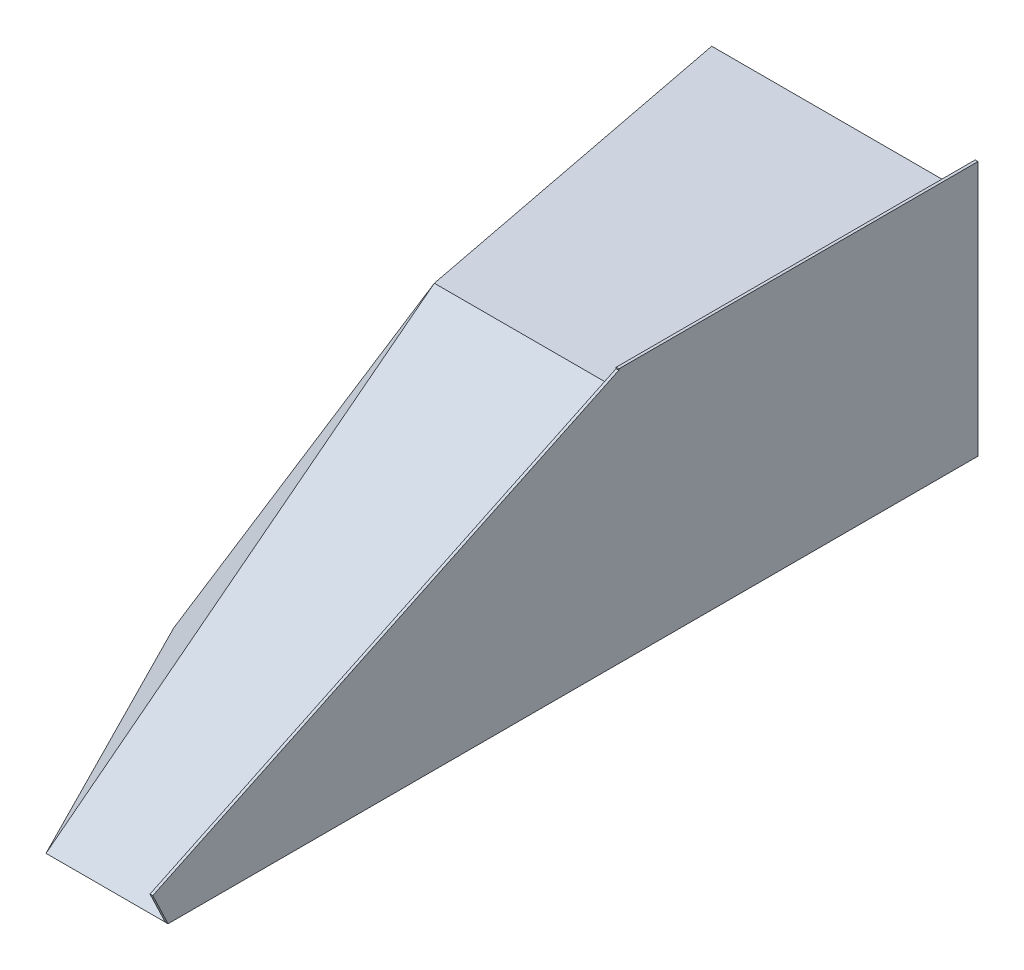
from build123d import *

# Parameters (mm, degrees)
BOSS_EXTRUDE1_DEPTH = 508
CUT_EXTRUDE1_DEPTH  = 508
BOSS_EXTRUDE2_DEPTH = 508
BOSS_EXTRUDE3_DEPTH = 635
CUT_EXTRUDE3_DEPTH  = 1016
CUT_EXTRUDE6_DEPTH  = 508
CUT_EXTRUDE7_DEPTH  = 1016
CUT_EXTRUDE8_DEPTH  = 1016
CUT_EXTRUDE9_DEPTH  = 1016
CUT_EXTRUDE10_DEPTH = 2092.737749488
SKETCH11_W          = 6.35
SKETCH11_H          = 822.114235363
BOSS_EXTRUDE4_DEPTH = 76.2
SKETCH12_W          = 6.35
SKETCH12_H          = 1181.577860321
BOSS_EXTRUDE5_DEPTH = 81.28


with BuildPart() as part:
    # Sketch1 → Boss-Extrude1 (new body)
    with BuildSketch(Plane(origin=(0, 0, 0), x_dir=(1, 0, 0), z_dir=(0, 1, 0))):
        Polygon((0, 1066.8), (0, 0), (279.4, 0), (457.2, 1066.8), align=None)
    boss_extrude1 = extrude(amount=BOSS_EXTRUDE1_DEPTH)

    # Sketch2 → Cut-Extrude1 (cut)
    with BuildSketch(Plane.ZY):
        Polygon((0, 0), (-1066.8, 508), (-1066.8, 732.672417782), (0, 732.672417782), align=None)
    cut_extrude1 = extrude(amount=-CUT_EXTRUDE1_DEPTH, mode=Mode.SUBTRACT)

    # Sketch3 → Boss-Extrude2 (add)
    with BuildSketch(Plane.XZ):
        Polygon((0, -1066.8), (0, -1854.2), (609.6, -1854.2), (457.2, -1066.8), align=None)
    boss_extrude2 = extrude(amount=-BOSS_EXTRUDE2_DEPTH)

    # Mirror1: Boss-Extrude1 across plane
    add(boss_extrude1.mirror(Plane(origin=(0, 508, -1066.8), x_dir=(0, 0, 1), z_dir=(1, 0, 0))))

    # Mirror1 2: Cut-Extrude1 across plane
    add(cut_extrude1.mirror(Plane(origin=(0, 508, -1066.8), x_dir=(0, 0, 1), z_dir=(1, 0, 0))), mode=Mode.SUBTRACT)


with BuildPart() as body_2:
    # Sketch4 → Boss-Extrude3 (new body)
    with BuildSketch(Plane.XZ):
        Polygon((279.4, 0), (758.024602406, -943.929756814), (824.163316724, -1854.2), (609.6, -1854.2), (473.605368522, -1854.2), (229.324151542, -858.00394067), align=None)
    boss_extrude3 = extrude(amount=-BOSS_EXTRUDE3_DEPTH)

    # Sketch5 → Cut-Extrude3 (cut)
    with BuildSketch(Plane(origin=(158.02566363, 112.959299077, 80.127753023), x_dir=(-0.31022668993908165, -0.22175505323400505, 0.924437178619848), z_dir=(-0.7520567447205982, -0.5375823192171424, -0.38133437136635806))):
        Polygon((-393.664649125, 703.625608499), (953.241894052, -176.928807588), (-1326.842790058, -923.556364957), (-2274.788319735, -628.326732027), (-2325.528348512, 172.375821483), align=None)
    cut_extrude3 = extrude(amount=-CUT_EXTRUDE3_DEPTH, mode=Mode.SUBTRACT)

    # Sketch6 → Cut-Extrude6 (cut)
    with BuildSketch(Plane(origin=(397.94007399, 254.27896004, 77.020659482), x_dir=(0.13564130705663138, 0.08667317707163243, -0.9869595717131874), z_dir=(0.8316697136780645, 0.5314270256083374, 0.16096833167962543))):
        Polygon((1082.533011894, 1261.854611528), (2538.800510351, 767.688534421), (2437.604130324, -1113.046367909), (306.999460867, -1023.580096849), align=None)
    cut_extrude6 = extrude(amount=CUT_EXTRUDE6_DEPTH, mode=Mode.SUBTRACT)

    # Sketch7 → Cut-Extrude7 (cut)
    with BuildSketch(Plane(origin=(0, 0, 0), x_dir=(1, 0, 0), z_dir=(0, 0.9028605188239303, 0.4299335803923477))):
        Polygon((0, 1181.577860321), (0, 0), (1197.045935399, 0), (1543.879463505, 955.927792479), (976.352766556, 2301.292030359), align=None)
    cut_extrude7 = extrude(amount=CUT_EXTRUDE7_DEPTH, mode=Mode.SUBTRACT)

    # Sketch8 → Cut-Extrude8 (cut)
    with BuildSketch(Plane(origin=(382.681643927, 161.632761359, 74.067414954), x_dir=(0.1616973556962576, 0.06829590736935992, -0.9844742933146776), z_dir=(0.9068988908525647, 0.38304573613058523, 0.1755288175843677))):
        Polygon((1197.556798458, 999.143883777), (2455.295967915, 323.49765858), (2410.705423203, -956.043074474), (776.288597468, -956.043074474), (430.351182168, -503.275200855), align=None)
    cut_extrude8 = extrude(amount=CUT_EXTRUDE8_DEPTH, mode=Mode.SUBTRACT)

    # Sketch9 → Cut-Extrude9 (cut)
    with BuildSketch(Plane(origin=(0, 508, 0), x_dir=(1, 0, 0), z_dir=(0, 1, 0))):
        Polygon((351.522364305, 2301.225932819), (1863.401978722, 1800.09916747), (1313.944223798, 629.194662402), (-286.938271333, 375.015467974), (-444.004316346, 1364.25568729), align=None)
    cut_extrude9 = extrude(amount=CUT_EXTRUDE9_DEPTH, mode=Mode.SUBTRACT)


with BuildPart() as part_1:
    add(part.part)

    # Mirror1 3: Boss-Extrude2, Boss-Extrude3 across plane
    add(boss_extrude2.mirror(Plane(origin=(0, 508, -1066.8), x_dir=(0, 0, 1), z_dir=(1, 0, 0))))
    add(boss_extrude3.mirror(Plane(origin=(0, 508, -1066.8), x_dir=(0, 0, 1), z_dir=(1, 0, 0))))

    # Mirror1 4: Cut-Extrude3, Cut-Extrude6, Cut-Extrude7, Cut-Extrude8, Cut-Extrude9 across plane
    add(cut_extrude3.mirror(Plane(origin=(0, 508, -1066.8), x_dir=(0, 0, 1), z_dir=(1, 0, 0))), mode=Mode.SUBTRACT)
    add(cut_extrude6.mirror(Plane(origin=(0, 508, -1066.8), x_dir=(0, 0, 1), z_dir=(1, 0, 0))), mode=Mode.SUBTRACT)
    add(cut_extrude7.mirror(Plane(origin=(0, 508, -1066.8), x_dir=(0, 0, 1), z_dir=(1, 0, 0))), mode=Mode.SUBTRACT)
    add(cut_extrude8.mirror(Plane(origin=(0, 508, -1066.8), x_dir=(0, 0, 1), z_dir=(1, 0, 0))), mode=Mode.SUBTRACT)
    add(cut_extrude9.mirror(Plane(origin=(0, 508, -1066.8), x_dir=(0, 0, 1), z_dir=(1, 0, 0))), mode=Mode.SUBTRACT)


with BuildPart() as cut_extrude10_tool:
    # Sketch10 → Cut-Extrude10 (new, through all)
    with BuildSketch(Plane(origin=(0, 0, 0), x_dir=(0, 0, -1), z_dir=(1, 0, 0))):
        Polygon((2306.148998717, 875.535830554), (458.236130604, 1137.326156156), (-514.568333215, 141.183628961), (336.70111329, -1596.655316262), (2036.802708671, -1025.71271333), (2740.096775658, -499.622195383), align=None)
    extrude(amount=CUT_EXTRUDE10_DEPTH)


with BuildPart() as part_2:
    add(part_1.part)

    # Cut-Extrude10: cut by cut_extrude10_tool
    add(cut_extrude10_tool.part, mode=Mode.SUBTRACT)

    # Sketch11 → Boss-Extrude4 (add)
    with BuildSketch(Plane(origin=(0, 508, 0), x_dir=(1, 0, 0), z_dir=(0, 1, 0))):
        with Locations((-3.175, 1443.142882319)):
            Rectangle(SKETCH11_W, SKETCH11_H)
    extrude(amount=BOSS_EXTRUDE4_DEPTH)

    # Sketch12 → Boss-Extrude5 (add)
    with BuildSketch(Plane(origin=(0, 0, 0), x_dir=(1, 0, 0), z_dir=(0, 0.9028605188239304, 0.42993358039234775))):
        with Locations((-3.175, 590.788930161)):
            Rectangle(SKETCH12_W, SKETCH12_H)
    extrude(amount=BOSS_EXTRUDE5_DEPTH)


with BuildPart() as body_2_1:
    add(body_2.part)

    # Cut-Extrude10: cut by cut_extrude10_tool
    add(cut_extrude10_tool.part, mode=Mode.SUBTRACT)


solid = part_2.part
